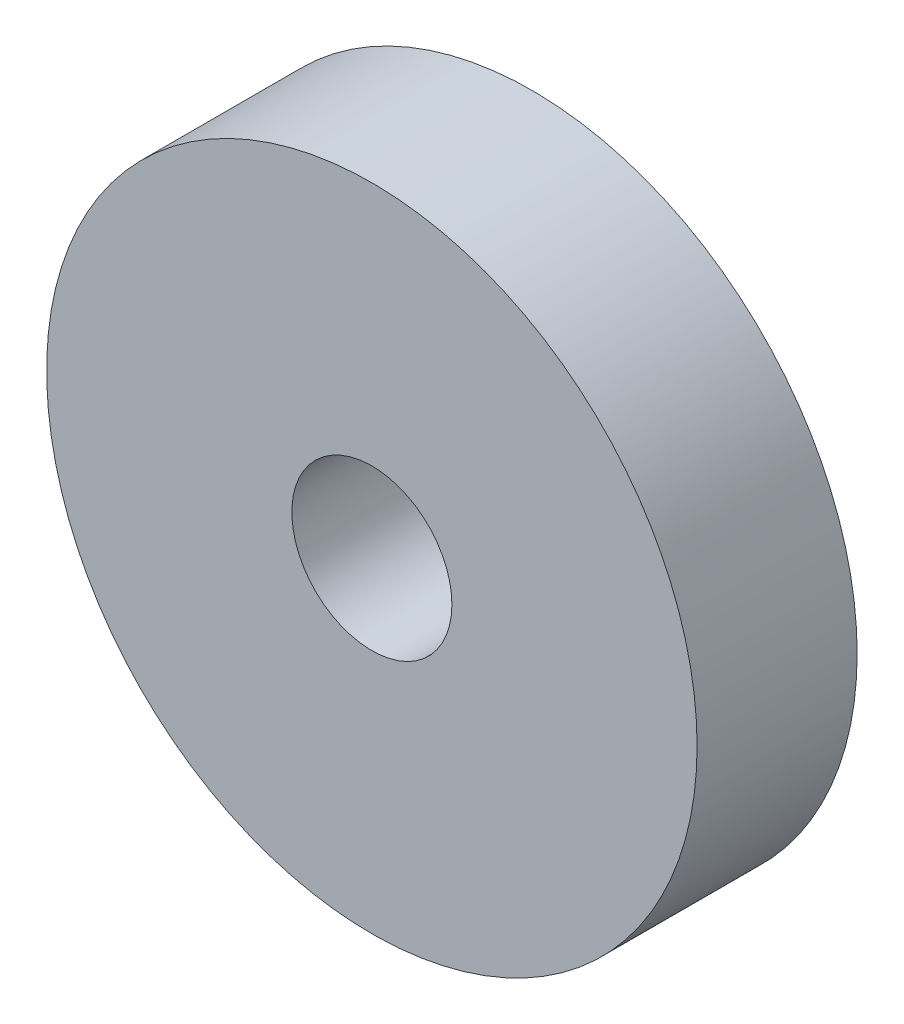
from build123d import *

# Parameters (mm, degrees)
SKETCH1_R           = 6.4516
SKETCH1_R_2         = 1.5875
BOSS_EXTRUDE1_DEPTH = 3.175


with BuildPart() as part:
    # Sketch1 → Boss-Extrude1 (new body)
    with BuildSketch(Plane.XY):
        Circle(SKETCH1_R)
        Circle(SKETCH1_R_2, mode=Mode.SUBTRACT)
    extrude(amount=BOSS_EXTRUDE1_DEPTH)


solid = part.part
